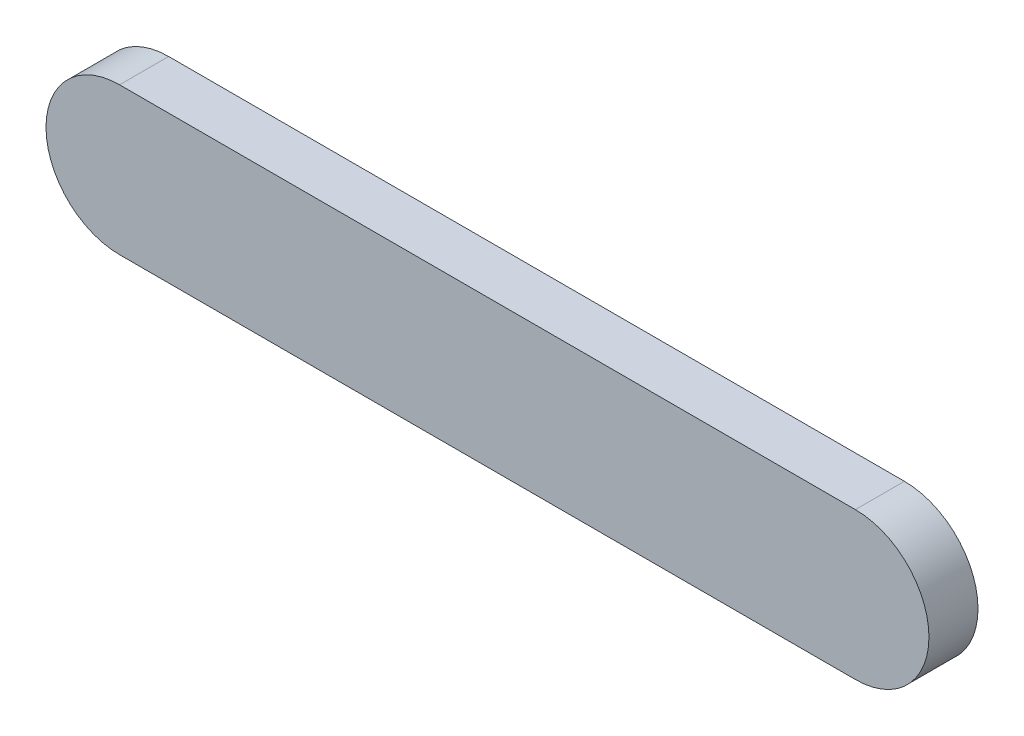
from build123d import *

# Parameters (mm, degrees)
BOSS_EXTRUDE1_DEPTH = 10


with BuildPart() as part:
    # Sketch1 → Boss-Extrude1 (new body)
    with BuildSketch(Plane.XY):
        with BuildLine():
            Line((0, 15), (150, 15))
            ThreePointArc((150, 15), (165, 0), (150, -15))
            Line((150, -15), (0, -15))
            ThreePointArc((0, -15), (-15, 0), (0, 15))
        make_face()
    extrude(amount=BOSS_EXTRUDE1_DEPTH)


solid = part.part
